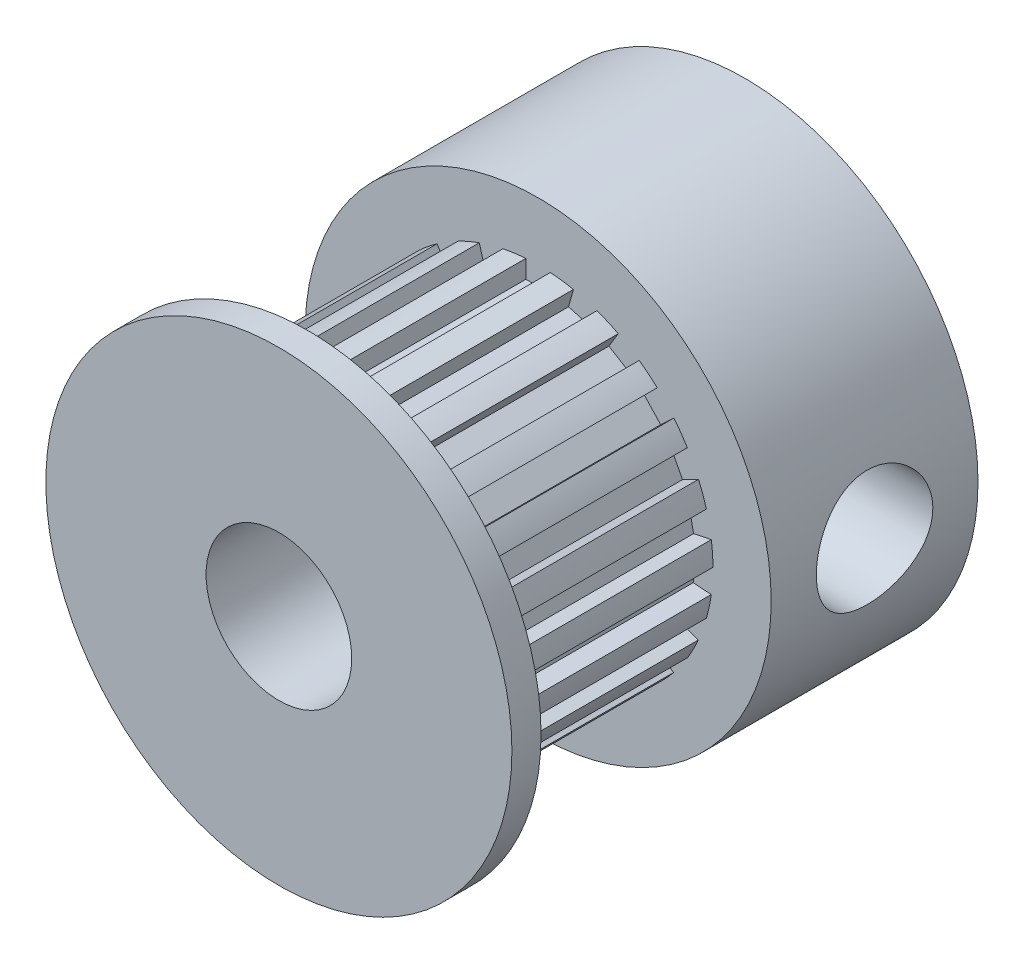
from build123d import *

# Parameters (mm, degrees)
SKETCH_1_R          = 8
EXTRUDE_1_DEPTH     = 7.1
SKETCH_2_R          = 6
EXTRUDE_2_DEPTH     = 7.9
SKETCH_3_R          = 8
EXTRUDE_3_DEPTH     = 1
SKETCH_4_W          = 0.839391048
SKETCH_4_H          = 1.04923881
CUT_EXTRUDE_1_DEPTH = 7.9
SKETCH_5_R          = 2.5
CUT_EXTRUDE_2_DEPTH = 21
CUT_EXTRUDE_3_REACH = 18
SKETCH_6_R          = 2
CUT_EXTRUDE_4_REACH = 18
SKETCH_7_R          = 2


with BuildPart() as part:
    # 草图1 → 凸台-拉伸1 (new body)
    with BuildSketch(Plane.XY):
        Circle(SKETCH_1_R)
    extrude(amount=EXTRUDE_1_DEPTH)

    # 草图2 → 凸台-拉伸2 (add)
    with BuildSketch(Plane.XY.offset(7.1)):
        Circle(SKETCH_2_R)
    extrude(amount=EXTRUDE_2_DEPTH)

    # 草图3 → 凸台-拉伸3 (add)
    with BuildSketch(Plane.XY.offset(15)):
        Circle(SKETCH_3_R)
    extrude(amount=EXTRUDE_3_DEPTH)

    # 草图4 → 切除-拉伸1 (cut)
    with BuildSketch(Plane.XY.offset(7.1)):
        Polygon((1.326202023, 6.288875776), (1.04312078, 5.278545587), (1.851384931, 5.052080593), (2.134466174, 6.062410781), align=None)
        with Locations((0, 5.888852821)):
            Rectangle(SKETCH_4_W, SKETCH_4_H)
        Polygon((2.973741233, 5.697862179), (2.428573588, 4.80137218), (3.145765587, 4.365238063), (3.690933233, 5.261728063), align=None)
        Polygon((4.40073166, 4.68426421), (3.633910202, 3.968102962), (4.206839201, 3.354645796), (4.973660658, 4.070807044), align=None)
        Polygon((5.501339951, 3.323255794), (4.569736321, 2.840537701), (4.955910795, 2.095254797), (5.887514425, 2.57797289), align=None)
        Polygon((6.193939026, 1.715776698), (5.166646002, 1.502302753), (5.337425159, 0.680468335), (6.364718182, 0.89394228), align=None)
        Polygon((6.427161978, -0.018953706), (5.380369186, 0.052648883), (5.323087115, -0.784785351), (6.369879907, -0.85638794), align=None)
        Polygon((6.183711728, -1.7522784), (5.195055, -1.400909715), (4.913960051, -2.191835098), (5.90261678, -2.543203783), align=None)
        Polygon((5.481643869, -3.355644622), (4.62444735, -2.750569247), (4.14038705, -3.436326462), (4.997583569, -4.041401837), align=None)
        Polygon((4.37302756, -4.710138033), (3.710865596, -3.896231641), (3.059740483, -4.425961212), (3.721902447, -5.239867604), align=None)
        Polygon((2.940083802, -5.715302054), (2.522065917, -4.752928359), (1.752166961, -5.087342668), (2.170184847, -6.049716362), align=None)
        Polygon((1.289087479, -6.296588267), (1.146216147, -5.257122124), (0.314643232, -5.37141919), (0.457514565, -6.410885333), align=None)
        Polygon((-0.457514565, -6.410885333), (-0.314643232, -5.37141919), (-1.146216147, -5.257122124), (-1.289087479, -6.296588267), align=None)
        Polygon((-2.170184847, -6.049716362), (-1.752166961, -5.087342668), (-2.522065917, -4.752928359), (-2.940083802, -5.715302054), align=None)
        Polygon((-3.721902447, -5.239867604), (-3.059740483, -4.425961212), (-3.710865596, -3.896231641), (-4.37302756, -4.710138033), align=None)
        Polygon((-4.997583569, -4.041401837), (-4.14038705, -3.436326462), (-4.62444735, -2.750569247), (-5.481643869, -3.355644622), align=None)
        Polygon((-5.90261678, -2.543203783), (-4.913960051, -2.191835098), (-5.195055, -1.400909715), (-6.183711728, -1.7522784), align=None)
        Polygon((-6.369879907, -0.85638794), (-5.323087115, -0.784785351), (-5.380369186, 0.052648883), (-6.427161978, -0.018953706), align=None)
        Polygon((-6.364718182, 0.89394228), (-5.337425159, 0.680468335), (-5.166646002, 1.502302753), (-6.193939026, 1.715776698), align=None)
        Polygon((-5.887514425, 2.57797289), (-4.955910795, 2.095254797), (-4.569736321, 2.840537701), (-5.501339951, 3.323255794), align=None)
        Polygon((-4.973660658, 4.070807044), (-4.206839201, 3.354645796), (-3.633910202, 3.968102962), (-4.40073166, 4.68426421), align=None)
        Polygon((-3.690933233, 5.261728063), (-3.145765587, 4.365238063), (-2.428573588, 4.80137218), (-2.973741233, 5.697862179), align=None)
        Polygon((-2.134466174, 6.062410781), (-1.851384931, 5.052080593), (-1.04312078, 5.278545587), (-1.326202023, 6.288875776), align=None)
    extrude(amount=CUT_EXTRUDE_1_DEPTH, mode=Mode.SUBTRACT)

    # 草图5 → 切除-拉伸2 (cut)
    with BuildSketch(Plane.XY.offset(16)):
        Circle(SKETCH_5_R)
    extrude(amount=-CUT_EXTRUDE_2_DEPTH, mode=Mode.SUBTRACT)

    # 草图6 → 切除-拉伸3 (cut, up to next)
    with BuildSketch(Plane(origin=(8, 0, 0), x_dir=(0, 0, -1), z_dir=(1, 0, 0)), mode=Mode.PRIVATE) as cut_extrude_3_sk1:
        with Locations((-3.55, 0)):
            Circle(SKETCH_6_R)
    cut_extrude_3_tool1 = extrude(cut_extrude_3_sk1.sketch, amount=-CUT_EXTRUDE_3_REACH, mode=Mode.PRIVATE) & part.part
    add(cut_extrude_3_tool1.solids().sort_by_distance((8, 0, 3.55))[0], mode=Mode.SUBTRACT)

    # 草图7 → 切除-拉伸4 (cut, up to next)
    with BuildSketch(Plane(origin=(0, -8, 0), x_dir=(-1, 0, 0), z_dir=(0, -1, 0)), mode=Mode.PRIVATE) as cut_extrude_4_sk1:
        with Locations((0, -3.55)):
            Circle(SKETCH_7_R)
    cut_extrude_4_tool1 = extrude(cut_extrude_4_sk1.sketch, amount=-CUT_EXTRUDE_4_REACH, mode=Mode.PRIVATE) & part.part
    add(cut_extrude_4_tool1.solids().sort_by_distance((0, -8, 3.55))[0], mode=Mode.SUBTRACT)


solid = part.part
